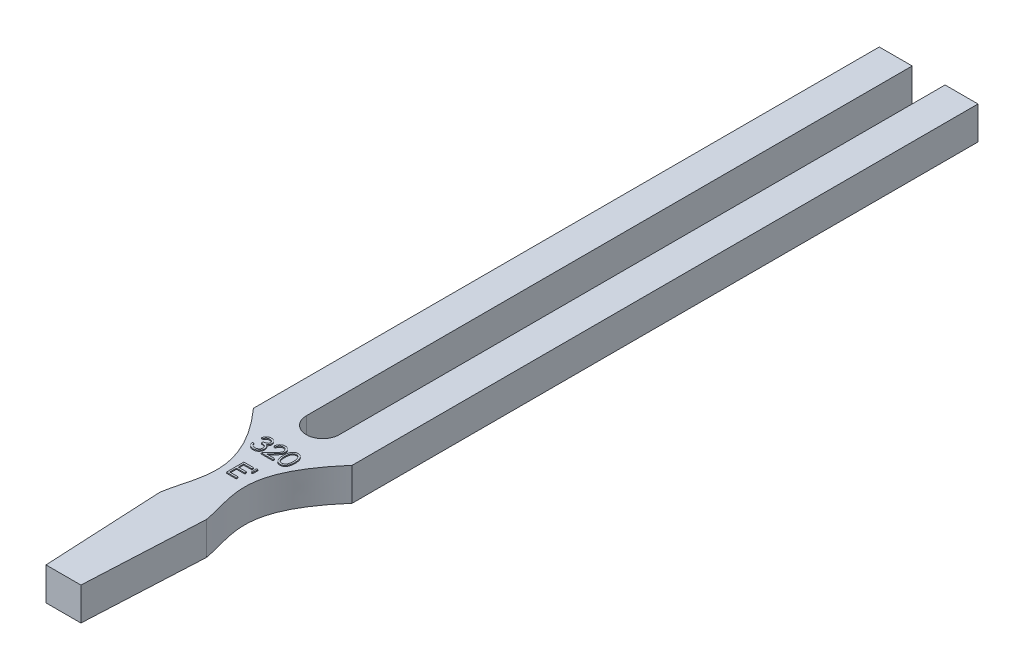
from build123d import *

# Parameters (mm, degrees)
BOSS_EXTRUDE1_DEPTH = 6.6
BOSS_EXTRUDE2_DEPTH = 0.2


with BuildPart() as part:
    # Sketch1 → Boss-Extrude1 (new body)
    with BuildSketch(Plane(origin=(0, 0, 0), x_dir=(1, 0, 0), z_dir=(0, 1, 0))):
        with BuildLine():
            Line((3.3, 121.5), (3.3, 0))
            ThreePointArc((3.3, 0), (0, -3.3), (-3.3, 0))
            Line((-3.3, 0), (-3.3, 121.5))
            Line((-3.3, 121.5), (-9.9, 121.5))
            Line((-9.9, 121.5), (-9.9, -4))
            add(Edge.make_bspline(
                [(-9.9, -4), (0.89859106, -16.071573054), (-3.763245474, -21.557189883), (-4.7, -28)],
                knots=[0, 0, 0, 0, 1, 1, 1, 1], degree=3))
            Line((-4.7, -28), (-3.5, -52))
            Line((-3.5, -52), (3.5, -52))
            Line((3.5, -52), (4.7, -28))
            add(Edge.make_bspline(
                [(9.9, -4), (-0.661663314, -16.124579678), (3.473758049, -21.278262187), (4.7, -28)],
                knots=[0, 0, 0, 0, 1, 1, 1, 1], degree=3))
            Line((9.9, -4), (9.9, 121.5))
            Line((9.9, 121.5), (3.3, 121.5))
        make_face()
    extrude(amount=BOSS_EXTRUDE1_DEPTH)

    # Sketch2 → Boss-Extrude2 (add)
    with BuildSketch(Plane(origin=(0, 6.6, 0), x_dir=(1, 0, 0), z_dir=(0, 1, 0))):
        with BuildLine():
            Line((-3.45138333, -8.471217952), (-3.765485894, -8.471217952))
            add(Edge.make_bspline(
                [(-3.765485894, -8.471217952), (-3.756976343, -8.435985468), (-3.740340868, -8.367108843), (-3.705643294, -8.268701582), (-3.667844039, -8.175578061), (-3.622454935, -8.089481987), (-3.57294618, -8.008683085), (-3.516223459, -7.93501396), (-3.454903736, -7.866600995), (-3.387078787, -7.805887757), (-3.315950125, -7.750910028), (-3.240515506, -7.704034971), (-3.162292612, -7.663710818), (-3.080739479, -7.630490586), (-2.995613307, -7.605465062), (-2.907683684, -7.587308257), (-2.816720184, -7.575517142), (-2.754972593, -7.574366379), (-2.723618907, -7.573782054)],
                knots=[0, 0, 0, 0, 0.000108665, 0.000212431, 0.000312691, 0.000409905, 0.000504067, 0.000596618, 0.000688443, 0.000779278, 0.000869306, 0.00095782, 0.001045306, 0.001133058, 0.001221569, 0.001311085, 0.001402223, 0.001496238, 0.001496238, 0.001496238, 0.001496238], degree=3))
            add(Edge.make_bspline(
                [(-2.723618907, -7.573782054), (-2.677936165, -7.575161285), (-2.587567154, -7.57788966), (-2.454804107, -7.602804096), (-2.326777288, -7.642229229), (-2.20488804, -7.696702956), (-2.091669607, -7.763890269), (-1.990933421, -7.843855006), (-1.90404491, -7.935054307), (-1.831150532, -8.035786872), (-1.774075533, -8.143442381), (-1.73198916, -8.254242538), (-1.706367479, -8.36792451), (-1.703046922, -8.444681789), (-1.70138333, -8.483137022)],
                knots=[0, 0, 0, 0, 0.000136936, 0.000270885, 0.000403723, 0.000538055, 0.000670441, 0.000797677, 0.000922646, 0.001047185, 0.00116951, 0.001287103, 0.001401935, 0.001517226, 0.001517226, 0.001517226, 0.001517226], degree=3))
            add(Edge.make_bspline(
                [(-1.70138333, -8.483137022), (-1.702546921, -8.520143817), (-1.704823888, -8.592560371), (-1.724157594, -8.698281869), (-1.756693857, -8.797923469), (-1.801763619, -8.891904631), (-1.860105169, -8.979629471), (-1.930777866, -9.061295362), (-2.014280528, -9.13726452), (-2.077559466, -9.180783993), (-2.110137336, -9.203189106)],
                knots=[0, 0, 0, 0, 0.000110957, 0.000217125, 0.000321111, 0.000424595, 0.000528824, 0.000636204, 0.000747885, 0.000866393, 0.000866393, 0.000866393, 0.000866393], degree=3))
            add(Edge.make_bspline(
                [(-2.110137336, -9.203189106), (-2.072905582, -9.221167277), (-1.999138707, -9.256787235), (-1.898588178, -9.326642992), (-1.807310303, -9.40729934), (-1.756406584, -9.470241992), (-1.730830445, -9.50186699)],
                knots=[0, 0, 0, 0, 0.000123863, 0.000245408, 0.000366052, 0.000487879, 0.000487879, 0.000487879, 0.000487879], degree=3))
            add(Edge.make_bspline(
                [(-1.730830445, -9.50186699), (-1.713989103, -9.524924742), (-1.680582207, -9.570662658), (-1.639346673, -9.644199084), (-1.601937559, -9.718550574), (-1.57278734, -9.79570998), (-1.550213473, -9.874782993), (-1.53407744, -9.955905389), (-1.5240533, -10.039143412), (-1.522617748, -10.095455892), (-1.52189615, -10.123762022)],
                knots=[0, 0, 0, 0, 8.5583e-05, 0.000169764, 0.000252544, 0.000335098, 0.000416766, 0.000498992, 0.000583001, 0.000667909, 0.000667909, 0.000667909, 0.000667909], degree=3))
            add(Edge.make_bspline(
                [(-1.52189615, -10.123762022), (-1.523690664, -10.172771743), (-1.527271246, -10.270560545), (-1.55927532, -10.415035267), (-1.608888561, -10.556260769), (-1.679345497, -10.691335608), (-1.765213006, -10.817715989), (-1.86737033, -10.930792298), (-1.984656738, -11.027990903), (-2.115462387, -11.109201131), (-2.257179516, -11.174119053), (-2.408755108, -11.219176496), (-2.568005162, -11.248522496), (-2.677212459, -11.251669364), (-2.73273349, -11.253269234)],
                knots=[0, 0, 0, 0, 0.000146863, 0.000293035, 0.000441833, 0.000594857, 0.000748684, 0.000899086, 0.001050437, 0.001204129, 0.001359752, 0.001516561, 0.001677477, 0.001843893, 0.001843893, 0.001843893, 0.001843893], degree=3))
            add(Edge.make_bspline(
                [(-2.73273349, -11.253269234), (-2.77015279, -11.25240102), (-2.843781496, -11.250692666), (-2.952024994, -11.239014065), (-3.055346693, -11.21768406), (-3.153886291, -11.188980755), (-3.247731328, -11.152589012), (-3.336595433, -11.107270314), (-3.421025326, -11.053958812), (-3.500224277, -10.992025225), (-3.574182845, -10.922743885), (-3.640935569, -10.844884875), (-3.701595362, -10.759887471), (-3.754538001, -10.666764415), (-3.802174954, -10.566719157), (-3.84135591, -10.458470659), (-3.875841479, -10.342986637), (-3.891874943, -10.262508897), (-3.900101279, -10.221217952)],
                knots=[0, 0, 0, 0, 0.000112258, 0.000220887, 0.000326076, 0.000428356, 0.000528479, 0.000627563, 0.000727152, 0.000827569, 0.00092875, 0.001030654, 0.001134734, 0.001241526, 0.001351611, 0.001466743, 0.00158655, 0.001712791, 0.001712791, 0.001712791, 0.001712791], degree=3))
            Line((-3.900101279, -10.221217952), (-3.585998715, -10.221217952))
            add(Edge.make_bspline(
                [(-3.585998715, -10.221217952), (-3.577815423, -10.248166965), (-3.56189821, -10.300585137), (-3.534803912, -10.376025442), (-3.50393564, -10.445183495), (-3.470821082, -10.508566617), (-3.436042636, -10.56679902), (-3.397127711, -10.618340889), (-3.356958565, -10.665456091), (-3.326679212, -10.692000703), (-3.311860093, -10.70499199)],
                knots=[0, 0, 0, 0, 8.4487e-05, 0.000164335, 0.000240293, 0.00031148, 0.000378817, 0.000443461, 0.000505064, 0.000564113, 0.000564113, 0.000564113, 0.000564113], degree=3))
            add(Edge.make_bspline(
                [(-3.311860093, -10.70499199), (-3.292263516, -10.720100324), (-3.253130853, -10.750270356), (-3.189362622, -10.788771984), (-3.122297736, -10.82213301), (-3.050483062, -10.847616705), (-2.975468291, -10.869194366), (-2.896040926, -10.883314885), (-2.812901709, -10.893003057), (-2.756133946, -10.893857988), (-2.727124516, -10.894294875)],
                knots=[0, 0, 0, 0, 7.418e-05, 0.000148131, 0.000223072, 0.000298488, 0.0003764, 0.000456984, 0.000540217, 0.000627201, 0.000627201, 0.000627201, 0.000627201], degree=3))
            add(Edge.make_bspline(
                [(-2.727124516, -10.894294875), (-2.694371013, -10.89367897), (-2.630324366, -10.89247462), (-2.536869507, -10.881398913), (-2.447962059, -10.8652685), (-2.364589134, -10.840355517), (-2.285658626, -10.809574665), (-2.212276977, -10.77092626), (-2.14348087, -10.725581538), (-2.080151465, -10.67404238), (-2.023205957, -10.617620885), (-1.973066444, -10.558607814), (-1.930441783, -10.497251984), (-1.896058205, -10.433213863), (-1.868907654, -10.366758634), (-1.850424454, -10.297699805), (-1.837572939, -10.226602539), (-1.836526326, -10.17827357), (-1.835998715, -10.153910259)],
                knots=[0, 0, 0, 0, 9.822e-05, 0.00019206, 0.00028199, 0.000368957, 0.000452673, 0.000535779, 0.000617257, 0.000699492, 0.000780303, 0.000857417, 0.000931514, 0.001003978, 0.001075065, 0.001146335, 0.001218144, 0.001291145, 0.001291145, 0.001291145, 0.001291145], degree=3))
            add(Edge.make_bspline(
                [(-1.835998715, -10.153910259), (-1.837529016, -10.121298921), (-1.840582005, -10.056238512), (-1.863890584, -9.960520938), (-1.902229448, -9.868297526), (-1.95590196, -9.781141735), (-2.021237688, -9.700365834), (-2.097602595, -9.628294351), (-2.185630823, -9.56882426), (-2.266650692, -9.527735604), (-2.338415849, -9.499698529), (-2.399831233, -9.481023564), (-2.468587837, -9.465209909), (-2.543854186, -9.450497637), (-2.626197402, -9.437976289), (-2.71552784, -9.427534473), (-2.811863602, -9.419179432), (-2.878554768, -9.415448337), (-2.912921791, -9.413525644)],
                knots=[0, 0, 0, 0, 9.7761e-05, 0.000195035, 0.000293731, 0.000396299, 0.00050098, 0.000604654, 0.000710058, 0.000818548, 0.000876487, 0.000941025, 0.001010919, 0.001088059, 0.001171055, 0.001260716, 0.001357836, 0.001461094, 0.001461094, 0.001461094, 0.001461094], degree=3))
            Line((-2.912921791, -9.413525644), (-2.912921791, -9.054551285))
            add(Edge.make_bspline(
                [(-2.912921791, -9.054551285), (-2.869620626, -9.053816481), (-2.784804279, -9.052377181), (-2.660909974, -9.034969171), (-2.542436662, -9.010888543), (-2.43200992, -8.974003351), (-2.331361207, -8.931163054), (-2.244041605, -8.881310844), (-2.171274458, -8.825896095), (-2.113413386, -8.764063486), (-2.069884157, -8.697748438), (-2.03805736, -8.62863178), (-2.019257034, -8.55610772), (-2.016747367, -8.506613052), (-2.015485894, -8.481734779)],
                knots=[0, 0, 0, 0, 0.0001298, 0.000254247, 0.000374709, 0.000491998, 0.000602842, 0.000702416, 0.000792872, 0.000876214, 0.000955164, 0.001029842, 0.001103644, 0.00117823, 0.00117823, 0.00117823, 0.00117823], degree=3))
            add(Edge.make_bspline(
                [(-2.015485894, -8.481734779), (-2.015900305, -8.463457033), (-2.016724756, -8.427094326), (-2.027122034, -8.373969258), (-2.042746075, -8.322468312), (-2.064225804, -8.272810502), (-2.092976003, -8.225340228), (-2.127381989, -8.179652779), (-2.16835009, -8.136009), (-2.215295537, -8.09532868), (-2.265707342, -8.056559443), (-2.320957117, -8.023645806), (-2.379378991, -7.995500744), (-2.441037646, -7.972291242), (-2.506133176, -7.954831954), (-2.574359734, -7.942296112), (-2.645847418, -7.934458457), (-2.69461915, -7.933330042), (-2.719412176, -7.932756413)],
                knots=[0, 0, 0, 0, 5.4759e-05, 0.000108941, 0.000161726, 0.000216044, 0.000270754, 0.000327825, 0.00038735, 0.000449943, 0.000514025, 0.000577874, 0.000642472, 0.000708366, 0.000775209, 0.000844379, 0.000916308, 0.00099068, 0.00099068, 0.00099068, 0.00099068], degree=3))
            add(Edge.make_bspline(
                [(-2.719412176, -7.932756413), (-2.759263844, -7.934147775), (-2.83710342, -7.936865429), (-2.949318337, -7.960668442), (-3.053637671, -7.998646526), (-3.133376338, -8.043979545), (-3.192258912, -8.088729979), (-3.23433585, -8.127812365), (-3.275656361, -8.171245189), (-3.313502038, -8.221703564), (-3.351776014, -8.275770355), (-3.386620576, -8.336194036), (-3.420480268, -8.40139843), (-3.440882818, -8.447494065), (-3.45138333, -8.471217952)],
                knots=[0, 0, 0, 0, 0.00011944, 0.000233294, 0.000342435, 0.0004514, 0.000506931, 0.000563998, 0.000623523, 0.000686492, 0.000753006, 0.000822147, 0.000895524, 0.000973336, 0.000973336, 0.000973336, 0.000973336], degree=3))
        make_face()
        with BuildLine():
            Line((-0.759075638, -8.740448721), (-1.073178202, -8.740448721))
            add(Edge.make_bspline(
                [(-1.073178202, -8.740448721), (-1.071131049, -8.698777833), (-1.067110495, -8.616937319), (-1.048282205, -8.497613412), (-1.021341328, -8.383558613), (-0.983249874, -8.275688699), (-0.935943596, -8.173049892), (-0.879213569, -8.076049877), (-0.812019719, -7.985058688), (-0.735812984, -7.900919845), (-0.653044345, -7.823732274), (-0.563738406, -7.757077031), (-0.469893379, -7.70075936), (-0.37179398, -7.653678118), (-0.268333416, -7.618338272), (-0.160450558, -7.592116632), (-0.047671422, -7.576340287), (0.0291686, -7.574644501), (0.06824808, -7.573782054)],
                knots=[0, 0, 0, 0, 0.000125083, 0.00024566, 0.000361805, 0.000476223, 0.000588214, 0.000700404, 0.000812728, 0.00092691, 0.001040529, 0.001151727, 0.001260545, 0.001368429, 0.001477521, 0.001587884, 0.001701119, 0.00181831, 0.00181831, 0.00181831, 0.00181831], degree=3))
            add(Edge.make_bspline(
                [(0.06824808, -7.573782054), (0.106626154, -7.574680511), (0.182037699, -7.576445946), (0.292099714, -7.591606975), (0.396877008, -7.615352566), (0.496164775, -7.648667983), (0.589170839, -7.69345241), (0.676593884, -7.747249949), (0.759474694, -7.80946978), (0.834081478, -7.882723594), (0.902589557, -7.960925978), (0.961691812, -8.044413882), (1.012304976, -8.130643167), (1.054492656, -8.220271369), (1.085548795, -8.314142397), (1.109127003, -8.4108896), (1.122454416, -8.511514411), (1.12449984, -8.579620967), (1.125539747, -8.614246798)],
                knots=[0, 0, 0, 0, 0.000115089, 0.000226145, 0.000332614, 0.000437044, 0.000539592, 0.000641561, 0.000744629, 0.00084975, 0.000954621, 0.001056175, 0.001156101, 0.001254284, 0.001352726, 0.001452208, 0.001552655, 0.001656537, 0.001656537, 0.001656537, 0.001656537], degree=3))
            add(Edge.make_bspline(
                [(1.125539747, -8.614246798), (1.123846484, -8.662994632), (1.120489673, -8.759634846), (1.091775296, -8.901649709), (1.046928785, -9.039243128), (0.992931428, -9.14998043), (0.938458984, -9.239213924), (0.889371477, -9.312682629), (0.831906666, -9.391788097), (0.765228168, -9.476265434), (0.690715295, -9.56677634), (0.607693132, -9.663266135), (0.51556965, -9.764737905), (0.450911149, -9.834043506), (0.417406734, -9.869955932)],
                knots=[0, 0, 0, 0, 0.000146118, 0.000289672, 0.0004329, 0.00057934, 0.000657978, 0.000746456, 0.000844345, 0.000951219, 0.001069268, 0.00119604, 0.001333047, 0.001480391, 0.001480391, 0.001480391, 0.001480391], degree=3))
            Line((0.417406734, -9.869955932), (-0.458294388, -10.804551285))
            Line((-0.458294388, -10.804551285), (1.170411542, -10.804551285))
            Line((1.170411542, -10.804551285), (1.170411542, -11.163525644))
            Line((1.170411542, -11.163525644), (-1.207793586, -11.163525644))
            Line((-1.207793586, -11.163525644), (0.149578209, -9.715008016))
            add(Edge.make_bspline(
                [(0.149578209, -9.715008016), (0.182626095, -9.680509709), (0.246104322, -9.614245523), (0.335886899, -9.517502563), (0.416525888, -9.427753022), (0.48854328, -9.345166473), (0.550376786, -9.268534906), (0.605249018, -9.200340202), (0.649214609, -9.137585752), (0.696930004, -9.064845138), (0.743143986, -8.976032821), (0.782856342, -8.867499131), (0.80707119, -8.755771879), (0.809976026, -8.680269842), (0.811437183, -8.64229167)],
                knots=[0, 0, 0, 0, 0.000143319, 0.000275286, 0.00039593, 0.000505287, 0.000603949, 0.000691331, 0.000767782, 0.00083371, 0.000952247, 0.001067137, 0.001179618, 0.001293462, 0.001293462, 0.001293462, 0.001293462], degree=3))
            add(Edge.make_bspline(
                [(0.811437183, -8.64229167), (0.810801441, -8.618410271), (0.809548515, -8.571344621), (0.798490817, -8.502338862), (0.781780311, -8.435774048), (0.757835053, -8.371445429), (0.726228313, -8.309999777), (0.687754933, -8.251362297), (0.64336487, -8.194673331), (0.5920136, -8.141520033), (0.53560208, -8.092838828), (0.476007831, -8.049714742), (0.412957727, -8.013675632), (0.346717604, -7.984132135), (0.277472135, -7.960956753), (0.20508739, -7.944898174), (0.129763374, -7.93481569), (0.078329878, -7.933451518), (0.052122279, -7.932756413)],
                knots=[0, 0, 0, 0, 7.16e-05, 0.00014111, 0.00020913, 0.00027724, 0.000346538, 0.000415963, 0.000487357, 0.000562233, 0.000637292, 0.000710646, 0.000782564, 0.000854749, 0.000927915, 0.001001225, 0.001076884, 0.001155488, 0.001155488, 0.001155488, 0.001155488], degree=3))
            add(Edge.make_bspline(
                [(0.052122279, -7.932756413), (0.024751446, -7.933471446), (-0.02900035, -7.934875651), (-0.107919383, -7.944698315), (-0.18320516, -7.961644155), (-0.255047063, -7.98482083), (-0.323566649, -8.014279378), (-0.388430693, -8.050971123), (-0.449493582, -8.094754616), (-0.506870106, -8.144395173), (-0.559734085, -8.199662774), (-0.606180961, -8.261272737), (-0.646764975, -8.328100152), (-0.682174208, -8.399964703), (-0.710929898, -8.477518483), (-0.732903049, -8.560486188), (-0.750289896, -8.648507569), (-0.756098416, -8.709292654), (-0.759075638, -8.740448721)],
                knots=[0, 0, 0, 0, 8.2106e-05, 0.000161243, 0.000238127, 0.000313291, 0.000387401, 0.000461495, 0.000536397, 0.000612445, 0.000688819, 0.000765383, 0.000843422, 0.000923066, 0.001005373, 0.001091093, 0.001180334, 0.001274175, 0.001274175, 0.001274175, 0.001274175], degree=3))
        make_face()
        with BuildLine():
            add(Edge.make_bspline(
                [(1.484514106, -9.414927888), (1.484842124, -9.3588305), (1.485479304, -9.249860516), (1.492567725, -9.091075874), (1.504343067, -8.942115585), (1.52048044, -8.802972519), (1.54011842, -8.673610754), (1.566333907, -8.554375997), (1.59614671, -8.44471639), (1.630699155, -8.344274342), (1.669686945, -8.251696639), (1.712121205, -8.165271437), (1.759686, -8.085129505), (1.809662913, -8.009991715), (1.864074984, -7.94108802), (1.921373775, -7.877445357), (1.983795651, -7.820534607), (2.049218659, -7.768688305), (2.118235124, -7.723238833), (2.18887779, -7.683206094), (2.261632896, -7.649006227), (2.336699078, -7.622115791), (2.413401636, -7.599904944), (2.492008703, -7.584715997), (2.572650067, -7.575159088), (2.627081502, -7.57424542), (2.654686382, -7.573782054)],
                knots=[0, 0, 0, 0, 0.000168282, 0.000326891, 0.000476705, 0.00061646, 0.000747059, 0.00086904, 0.000982494, 0.001087814, 0.001187428, 0.001283689, 0.001376399, 0.001466822, 0.001554203, 0.001639568, 0.001723424, 0.001807301, 0.001889751, 0.001971063, 0.002050735, 0.002130583, 0.002210036, 0.002290062, 0.002370508, 0.002453288, 0.002453288, 0.002453288, 0.002453288], degree=3))
            add(Edge.make_bspline(
                [(2.654686382, -7.573782054), (2.68252186, -7.574269869), (2.737877869, -7.57523998), (2.819718244, -7.584563923), (2.899667926, -7.600035046), (2.977386065, -7.621956021), (3.053511051, -7.649151697), (3.127447459, -7.683238814), (3.19965454, -7.722917682), (3.268984828, -7.769541559), (3.336199443, -7.821523835), (3.399647406, -7.880286504), (3.459334492, -7.945236223), (3.516009798, -8.015678087), (3.568065395, -8.092963172), (3.617638827, -8.175747282), (3.662010863, -8.265478147), (3.704745538, -8.360658614), (3.741632525, -8.463922273), (3.77489877, -8.574687034), (3.801777739, -8.694261221), (3.824167011, -8.822017466), (3.841511907, -8.958424949), (3.854144549, -9.103191265), (3.860817634, -9.256411655), (3.862074335, -9.361169504), (3.862719234, -9.414927888)],
                knots=[0, 0, 0, 0, 8.3481e-05, 0.000166017, 0.000246731, 0.000327534, 0.000408041, 0.000488986, 0.000571522, 0.000654944, 0.000739373, 0.000826202, 0.000914021, 0.001003809, 0.001097153, 0.001193347, 0.001293057, 0.001397277, 0.001506176, 0.001621751, 0.001744038, 0.001873599, 0.002010742, 0.002156422, 0.002309427, 0.002470709, 0.002470709, 0.002470709, 0.002470709], degree=3))
            add(Edge.make_bspline(
                [(3.862719234, -9.414927888), (3.86206765, -9.468451796), (3.860798064, -9.572740947), (3.854219357, -9.725271923), (3.841260726, -9.869269966), (3.825050737, -10.005080428), (3.802599774, -10.132138047), (3.774994608, -10.250882496), (3.744344285, -10.361826567), (3.706509491, -10.464061379), (3.665098781, -10.559013102), (3.620043585, -10.64768025), (3.571773759, -10.730846543), (3.519185014, -10.80784629), (3.463131601, -10.879224947), (3.402413812, -10.94372257), (3.338743227, -11.002893242), (3.271330811, -11.055544869), (3.20091926, -11.101629674), (3.128960183, -11.142843524), (3.054176799, -11.176076219), (2.978263847, -11.20461126), (2.90013548, -11.226411712), (2.81988909, -11.241485567), (2.737932854, -11.252057416), (2.682531289, -11.252863896), (2.654686382, -11.253269234)],
                knots=[0, 0, 0, 0, 0.000160581, 0.000312886, 0.000457868, 0.000594226, 0.000723097, 0.000844701, 0.000959884, 0.001068125, 0.001171421, 0.001270505, 0.001366343, 0.001459687, 0.001550023, 0.00163832, 0.001725149, 0.001810562, 0.001894568, 0.001977446, 0.00205903, 0.002139777, 0.00222058, 0.002301983, 0.002384599, 0.00246808, 0.00246808, 0.00246808, 0.00246808], degree=3))
            add(Edge.make_bspline(
                [(2.654686382, -11.253269234), (2.627082268, -11.252802878), (2.572652343, -11.251883316), (2.491999917, -11.242369585), (2.413717474, -11.227074082), (2.33741872, -11.205657478), (2.262712205, -11.179442641), (2.190615918, -11.145288958), (2.120328235, -11.105954889), (2.052036678, -11.061159467), (1.987024517, -11.009837784), (1.924925912, -10.953073495), (1.867300893, -10.889450084), (1.813666797, -10.819972161), (1.762692709, -10.745278919), (1.715803336, -10.664350546), (1.672432482, -10.577507935), (1.632788991, -10.484190024), (1.597640328, -10.383035097), (1.56659262, -10.272885918), (1.542078462, -10.152770282), (1.521095507, -10.023652915), (1.504171124, -9.884978985), (1.492616798, -9.736673206), (1.485475483, -9.578827997), (1.484840413, -9.470558223), (1.484514106, -9.414927888)],
                knots=[0, 0, 0, 0, 8.278e-05, 0.000163226, 0.000243252, 0.00032184, 0.00040079, 0.000480463, 0.00056082, 0.000642298, 0.000725191, 0.000809047, 0.000894412, 0.000982346, 0.001072188, 0.001165503, 0.001262704, 0.001363236, 0.001469448, 0.001583766, 0.001706286, 0.001836995, 0.001976138, 0.002125253, 0.002283161, 0.002450041, 0.002450041, 0.002450041, 0.002450041], degree=3))
        make_face()
        with BuildLine():
            add(Edge.make_bspline(
                [(1.79861667, -9.413525644), (1.798736117, -9.460274343), (1.79896794, -9.551004388), (1.805024141, -9.682847649), (1.813274373, -9.805817977), (1.82391567, -9.920071514), (1.839718619, -10.025221526), (1.857425407, -10.121991209), (1.878973496, -10.209868447), (1.904468514, -10.289456257), (1.933507611, -10.362105326), (1.965213475, -10.429706541), (1.999274198, -10.493058477), (2.037393348, -10.551592086), (2.078908411, -10.60549825), (2.12288167, -10.655731082), (2.170954255, -10.700528063), (2.237457997, -10.754254918), (2.325254472, -10.809774052), (2.435874927, -10.858120142), (2.549543378, -10.888502598), (2.626694628, -10.892366354), (2.665203209, -10.894294875)],
                knots=[0, 0, 0, 0, 0.000140231, 0.000272162, 0.000395845, 0.00050998, 0.000616273, 0.00071473, 0.000805025, 0.000887508, 0.000965234, 0.00103957, 0.001111417, 0.001180842, 0.001248855, 0.001315406, 0.001380877, 0.0014457, 0.001571746, 0.00169106, 0.001806864, 0.001922266, 0.001922266, 0.001922266, 0.001922266], degree=3))
            add(Edge.make_bspline(
                [(2.665203209, -10.894294875), (2.70396088, -10.892697094), (2.781396203, -10.889504831), (2.894529999, -10.858706094), (3.004360269, -10.812236554), (3.090432209, -10.757289049), (3.155914752, -10.704960719), (3.202831742, -10.660346071), (3.245893791, -10.610390204), (3.286735866, -10.556490908), (3.324194941, -10.497618424), (3.358258079, -10.434055848), (3.389341427, -10.365626671), (3.407050473, -10.317856931), (3.416104651, -10.293433497)],
                knots=[0, 0, 0, 0, 0.000116044, 0.000231848, 0.000349318, 0.000472837, 0.000536674, 0.000600645, 0.000666733, 0.000734322, 0.000803367, 0.000875831, 0.000950509, 0.001028633, 0.001028633, 0.001028633, 0.001028633], degree=3))
            add(Edge.make_bspline(
                [(3.416104651, -10.293433497), (3.426656419, -10.262203757), (3.448081032, -10.198793993), (3.475692807, -10.100430341), (3.497438206, -9.997227577), (3.517001572, -9.88980246), (3.530354628, -9.777362759), (3.541102441, -9.660256375), (3.547433128, -9.538395013), (3.548217879, -9.455600022), (3.54861667, -9.413525644)],
                knots=[0, 0, 0, 0, 9.8886e-05, 0.00020078, 0.000306259, 0.000415188, 0.00052824, 0.000645799, 0.000767957, 0.000894177, 0.000894177, 0.000894177, 0.000894177], degree=3))
            add(Edge.make_bspline(
                [(3.54861667, -9.413525644), (3.548066481, -9.371458071), (3.546990193, -9.289164907), (3.542876205, -9.168646726), (3.532252631, -9.054178965), (3.520453512, -8.945268492), (3.503056291, -8.84251819), (3.484298484, -8.745067885), (3.459097272, -8.65412486), (3.432177497, -8.568265278), (3.401367101, -8.488464623), (3.367451367, -8.414350837), (3.331229608, -8.345566112), (3.291887368, -8.282299171), (3.249891685, -8.224266628), (3.204134136, -8.172632033), (3.156429763, -8.125795065), (3.089612577, -8.072332496), (3.002138287, -8.017820801), (2.89329264, -7.967655041), (2.780021995, -7.938846748), (2.703448541, -7.934785061), (2.665203209, -7.932756413)],
                knots=[0, 0, 0, 0, 0.000126219, 0.000246912, 0.000361616, 0.00047102, 0.00057545, 0.000674176, 0.000768567, 0.000858368, 0.000944043, 0.001024988, 0.001102772, 0.001177091, 0.00124833, 0.001317386, 0.001383826, 0.001448649, 0.001573728, 0.001692043, 0.001806995, 0.001921698, 0.001921698, 0.001921698, 0.001921698], degree=3))
            add(Edge.make_bspline(
                [(2.665203209, -7.932756413), (2.626492616, -7.93478786), (2.549000911, -7.938854454), (2.434552956, -7.967547708), (2.324848604, -8.017560674), (2.23760563, -8.072513046), (2.170741843, -8.124851357), (2.12365915, -8.170237811), (2.079512978, -8.219884066), (2.038845278, -8.274285981), (2.000755994, -8.332751348), (1.965774982, -8.395740113), (1.934257652, -8.463571477), (1.905173116, -8.536187912), (1.879600328, -8.615768857), (1.858506365, -8.70353785), (1.839019312, -8.799999742), (1.825224043, -8.90571925), (1.812960287, -9.020001404), (1.805078939, -9.143278722), (1.798947681, -9.275343102), (1.798729217, -9.366542261), (1.79861667, -9.413525644)],
                knots=[0, 0, 0, 0, 0.000116101, 0.000232413, 0.000351368, 0.000476447, 0.000540832, 0.000605795, 0.000672346, 0.000739935, 0.00080936, 0.000881545, 0.00095588, 0.001033607, 0.001116089, 0.001206384, 0.001304286, 0.001411174, 0.001526077, 0.001649061, 0.001781692, 0.001922624, 0.001922624, 0.001922624, 0.001922624], degree=3))
        make_face(mode=Mode.SUBTRACT)
        Polygon((-1.319973074, -14.496858977), (0.654385901, -14.496858977), (0.654385901, -14.855833336), (-1.005870509, -14.855833336), (-1.005870509, -15.932756413), (0.654385901, -15.932756413), (0.654385901, -16.291730772), (-1.005870509, -16.291730772), (-1.005870509, -17.637884618), (0.654385901, -17.637884618), (0.654385901, -17.996858977), (-1.319973074, -17.996858977), align=None)
        Polygon((1.368127888, -15.484038465), (1.15007901, -15.484038465), (1.10310385, -14.407115388), (1.417206414, -14.407115388), align=None)
    extrude(amount=BOSS_EXTRUDE2_DEPTH)


solid = part.part
